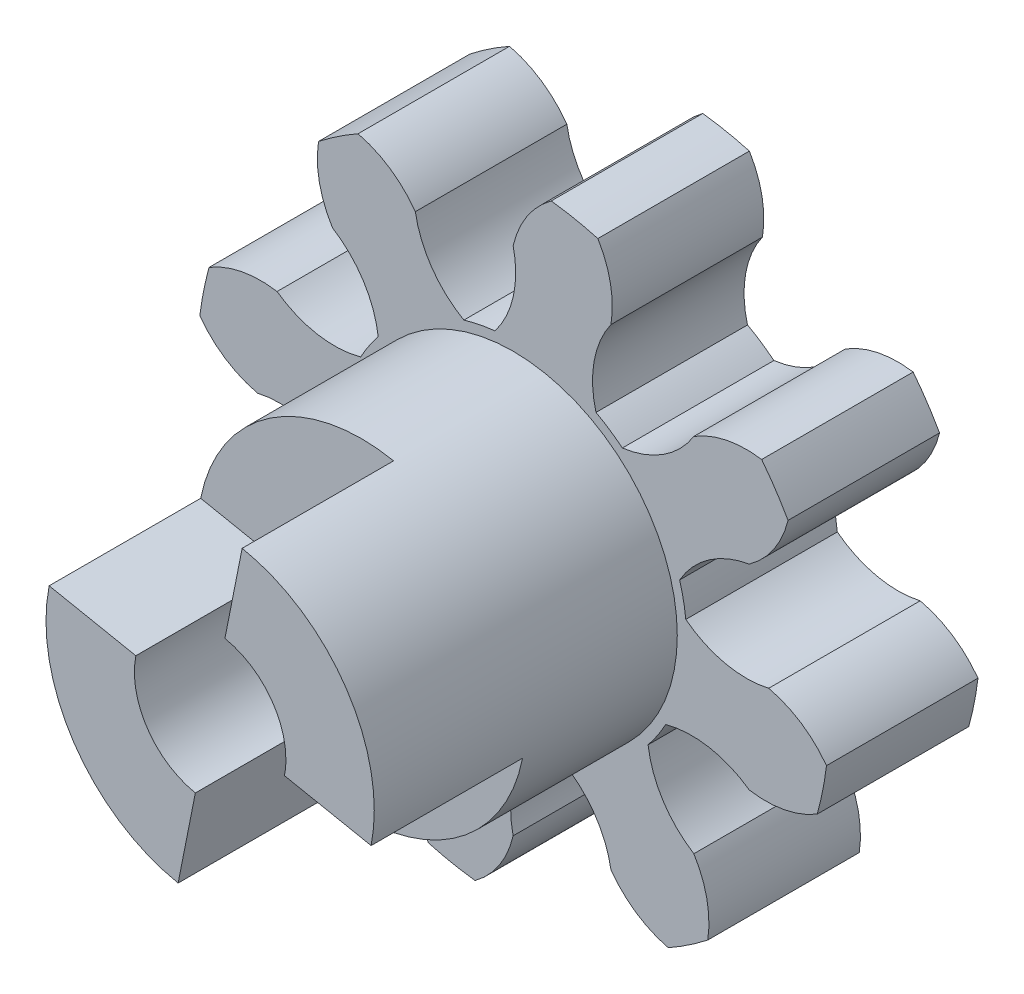
from build123d import *

# Parameters (mm, degrees)
SALIENTE_EXTRUIR1_DEPTH = 3
CROQUIS2_R              = 3.25
SALIENTE_EXTRUIR2_DEPTH = 3
CROQUIS3_R              = 3.25
SALIENTE_EXTRUIR3_DEPTH = 3
CORTAR_EXTRUIR2_DEPTH   = 3
CROQUIS6_R              = 1.5
CORTAR_EXTRUIR3_DEPTH   = 10


with BuildPart() as part:
    # Croquis1 → Saliente-Extruir1 (new body)
    with BuildSketch(Plane.XY):
        with BuildLine():
            ThreePointArc((3.41860772, 0.359899305), (4.198868033, -0.004516375), (5.060021066, 0))
            ThreePointArc((5.060021066, 0), (5.700122231, -0.2741037), (6.204306422, -0.754375124))
            ThreePointArc((6.204306422, -0.754375124), (6.129908003, -1.219314513), (6.020718578, -1.67733354))
            ThreePointArc((6.020718578, -1.67733354), (5.371121207, -1.928103542), (4.674849897, -1.93638623))
            ThreePointArc((4.674849897, -1.93638623), (3.880976577, -1.602664645), (3.020654201, -1.640748138))
            ThreePointArc((3.020654201, -1.640748138), (2.858176792, -1.909772676), (2.67180794, -2.162833462))
            ThreePointArc((2.67180794, -2.162833462), (2.9658545, -2.972241619), (3.577975209, -3.577975209))
            ThreePointArc((3.577975209, -3.577975209), (3.836774498, -4.224415668), (3.853683377, -4.920530909))
            ThreePointArc((3.853683377, -4.920530909), (3.472313956, -5.196685077), (3.071237014, -5.443344854))
            ThreePointArc((3.071237014, -5.443344854), (2.434581138, -5.161331317), (1.93638623, -4.674849897))
            ThreePointArc((1.93638623, -4.674849897), (1.611009817, -3.877519894), (0.975740935, -3.296109203))
            ThreePointArc((0.975740935, -3.296109203), (0.670622982, -3.371449401), (0.359899305, -3.41860772))
            ThreePointArc((0.359899305, -3.41860772), (-0.004516375, -4.198868033), (0, -5.060021066))
            ThreePointArc((0, -5.060021066), (-0.2741037, -5.700122231), (-0.754375124, -6.204306422))
            ThreePointArc((-0.754375124, -6.204306422), (-1.219314513, -6.129908003), (-1.67733354, -6.020718578))
            ThreePointArc((-1.67733354, -6.020718578), (-1.928103542, -5.371121207), (-1.93638623, -4.674849897))
            ThreePointArc((-1.93638623, -4.674849897), (-1.602664645, -3.880976577), (-1.640748138, -3.020654201))
            ThreePointArc((-1.640748138, -3.020654201), (-1.909772676, -2.858176792), (-2.162833462, -2.67180794))
            ThreePointArc((-2.162833462, -2.67180794), (-2.972241619, -2.9658545), (-3.577975209, -3.577975209))
            ThreePointArc((-3.577975209, -3.577975209), (-4.224415668, -3.836774498), (-4.920530909, -3.853683377))
            ThreePointArc((-4.920530909, -3.853683377), (-5.196685077, -3.472313956), (-5.443344854, -3.071237014))
            ThreePointArc((-5.443344854, -3.071237014), (-5.161331317, -2.434581138), (-4.674849897, -1.93638623))
            ThreePointArc((-4.674849897, -1.93638623), (-3.877519894, -1.611009817), (-3.296109203, -0.975740935))
            ThreePointArc((-3.296109203, -0.975740935), (-3.371449401, -0.670622982), (-3.41860772, -0.359899305))
            ThreePointArc((-3.41860772, -0.359899305), (-4.198868033, 0.004516375), (-5.060021066, 0))
            ThreePointArc((-5.060021066, 0), (-5.700122231, 0.2741037), (-6.204306422, 0.754375124))
            ThreePointArc((-6.204306422, 0.754375124), (-6.129908003, 1.219314513), (-6.020718578, 1.67733354))
            ThreePointArc((-6.020718578, 1.67733354), (-5.371121207, 1.928103542), (-4.674849897, 1.93638623))
            ThreePointArc((-4.674849897, 1.93638623), (-3.880976577, 1.602664645), (-3.020654201, 1.640748138))
            ThreePointArc((-3.020654201, 1.640748138), (-2.858176792, 1.909772676), (-2.67180794, 2.162833462))
            ThreePointArc((-2.67180794, 2.162833462), (-2.9658545, 2.972241619), (-3.577975209, 3.577975209))
            ThreePointArc((-3.577975209, 3.577975209), (-3.836774498, 4.224415668), (-3.853683377, 4.920530909))
            ThreePointArc((-3.853683377, 4.920530909), (-3.472313956, 5.196685077), (-3.071237014, 5.443344854))
            ThreePointArc((-3.071237014, 5.443344854), (-2.434581138, 5.161331317), (-1.93638623, 4.674849897))
            ThreePointArc((-1.93638623, 4.674849897), (-1.611009817, 3.877519894), (-0.975740935, 3.296109203))
            ThreePointArc((-0.975740935, 3.296109203), (-0.670622982, 3.371449401), (-0.359899305, 3.41860772))
            ThreePointArc((-0.359899305, 3.41860772), (0.004516375, 4.198868033), (0, 5.060021066))
            ThreePointArc((0, 5.060021066), (0.2741037, 5.700122231), (0.754375124, 6.204306422))
            ThreePointArc((0.754375124, 6.204306422), (1.219314513, 6.129908003), (1.67733354, 6.020718578))
            ThreePointArc((1.67733354, 6.020718578), (1.928103542, 5.371121207), (1.93638623, 4.674849897))
            ThreePointArc((1.93638623, 4.674849897), (1.602664645, 3.880976577), (1.640748138, 3.020654201))
            ThreePointArc((1.640748138, 3.020654201), (1.909772676, 2.858176792), (2.162833462, 2.67180794))
            ThreePointArc((2.162833462, 2.67180794), (2.972241619, 2.9658545), (3.577975209, 3.577975209))
            ThreePointArc((3.577975209, 3.577975209), (4.224415668, 3.836774498), (4.920530909, 3.853683377))
            ThreePointArc((4.920530909, 3.853683377), (5.196685077, 3.472313956), (5.443344854, 3.071237014))
            ThreePointArc((5.443344854, 3.071237014), (5.161331317, 2.434581138), (4.674849897, 1.93638623))
            ThreePointArc((4.674849897, 1.93638623), (3.877519894, 1.611009817), (3.296109203, 0.975740935))
            ThreePointArc((3.296109203, 0.975740935), (3.371449401, 0.670622982), (3.41860772, 0.359899305))
        make_face()
    extrude(amount=SALIENTE_EXTRUIR1_DEPTH)

    # Croquis2 → Saliente-Extruir2 (add)
    with BuildSketch(Plane.XY.offset(3)):
        Circle(CROQUIS2_R)
    extrude(amount=SALIENTE_EXTRUIR2_DEPTH)

    # Croquis3 → Saliente-Extruir3 (add)
    with BuildSketch(Plane.XY.offset(6)):
        Circle(CROQUIS3_R)
    extrude(amount=SALIENTE_EXTRUIR3_DEPTH)

    # Croquis4 → Cortar-Extruir2 (cut)
    with BuildSketch(Plane.XY.offset(9)):
        with BuildLine():
            Line((0.292635483, 1.471177921), (1.219314513, 6.129908003))
            Line((1.219314513, 6.129908003), (-6.129908003, 1.219314513))
            Line((-6.129908003, 1.219314513), (-1.471177921, 0.292635483))
            ThreePointArc((-1.471177921, 0.292635483), (-1.247204418, -0.83335535), (-0.292635483, -1.471177921))
            Line((-0.292635483, -1.471177921), (-1.219314513, -6.129908003))
            Line((-1.219314513, -6.129908003), (6.129908003, -1.219314513))
            Line((6.129908003, -1.219314513), (1.471177921, -0.292635483))
            ThreePointArc((1.471177921, -0.292635483), (1.247204418, 0.83335535), (0.292635483, 1.471177921))
        make_face()
    extrude(amount=-CORTAR_EXTRUIR2_DEPTH, mode=Mode.SUBTRACT)

    # Croquis6 → Cortar-Extruir3 (cut)
    with BuildSketch(Plane.XY.offset(6)):
        Circle(CROQUIS6_R)
    extrude(amount=-CORTAR_EXTRUIR3_DEPTH, mode=Mode.SUBTRACT)


solid = part.part
